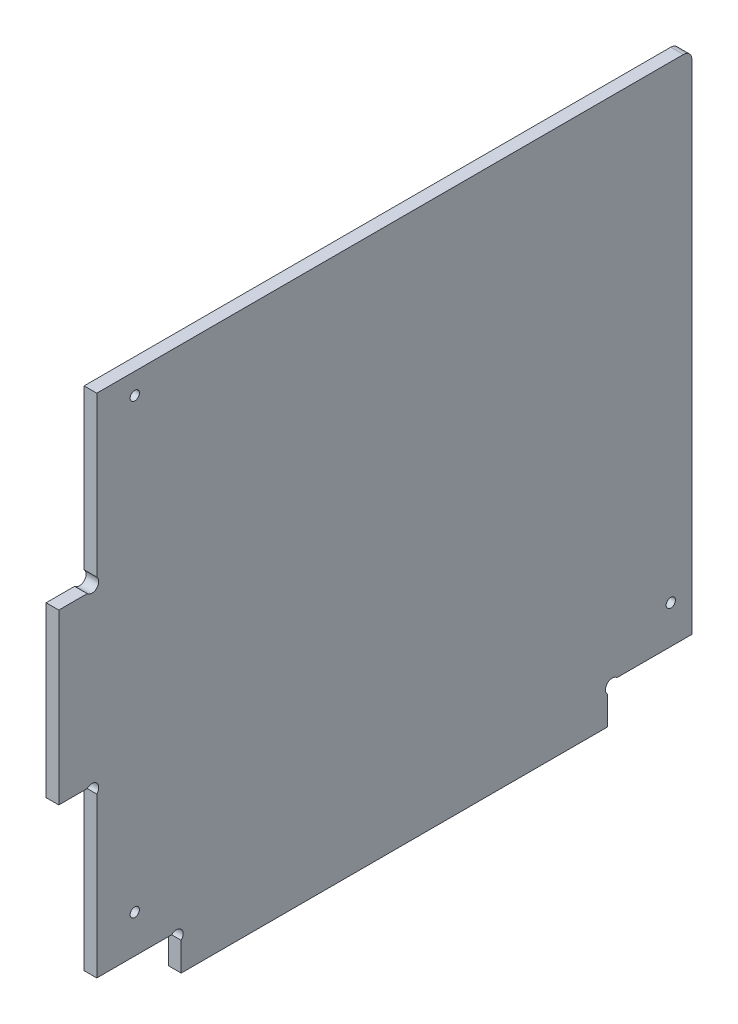
from build123d import *

# Parameters (mm, degrees)
EXTRUSION1_DEPTH        = 3
ESQUISSE2_R             = 1.1
ENL_V_MAT_EXTRU_1_DEPTH = 4
CONG_1_R                = 2


with BuildPart() as part:
    # Esquisse1 → Extrusion1 (new body)
    with BuildSketch(Plane(origin=(0, 0, 0), x_dir=(0, 0, -1), z_dir=(1, 0, 0))):
        with BuildLine():
            Line((130, 6.7372583), (130, 0))
            Line((130, 0), (29, 0))
            Line((29, 0), (29, 6.7372583))
            ThreePointArc((29, 6.7372583), (29, 9), (26.7372583, 9))
            Line((26.7372583, 9), (9, 9))
            Line((9, 9), (9, 46.7372583))
            ThreePointArc((9, 46.7372583), (9, 49), (6.7372583, 49))
            Line((6.7372583, 49), (0, 49))
            Line((0, 49), (0, 89))
            Line((0, 89), (6.7372583, 89))
            ThreePointArc((6.7372583, 89), (9, 89), (9, 91.2627417))
            Line((9, 91.2627417), (9, 129))
            Line((9, 129), (150, 129))
            Line((150, 129), (150, 9))
            Line((150, 9), (132.2627417, 9))
            ThreePointArc((132.2627417, 9), (130, 9), (130, 6.7372583))
        make_face()
    extrude(amount=EXTRUSION1_DEPTH)

    # Esquisse2 → Enlèv. mat.-Extru.1 (cut, through all)
    with BuildSketch(Plane(origin=(3, 0, 0), x_dir=(0, 0, -1), z_dir=(1, 0, 0))):
        with Locations((18, 124)):
            Circle(ESQUISSE2_R)
        with Locations((18, 18)):
            Circle(ESQUISSE2_R)
        with Locations((145, 18)):
            Circle(ESQUISSE2_R)
    extrude(amount=-ENL_V_MAT_EXTRU_1_DEPTH, mode=Mode.SUBTRACT)

    # Congé1
    cong_1_edges = [part.edges().sort_by_distance(p)[0] for p in [
        (1.5, 129, -150),
    ]]
    fillet(cong_1_edges, radius=CONG_1_R)


solid = part.part
